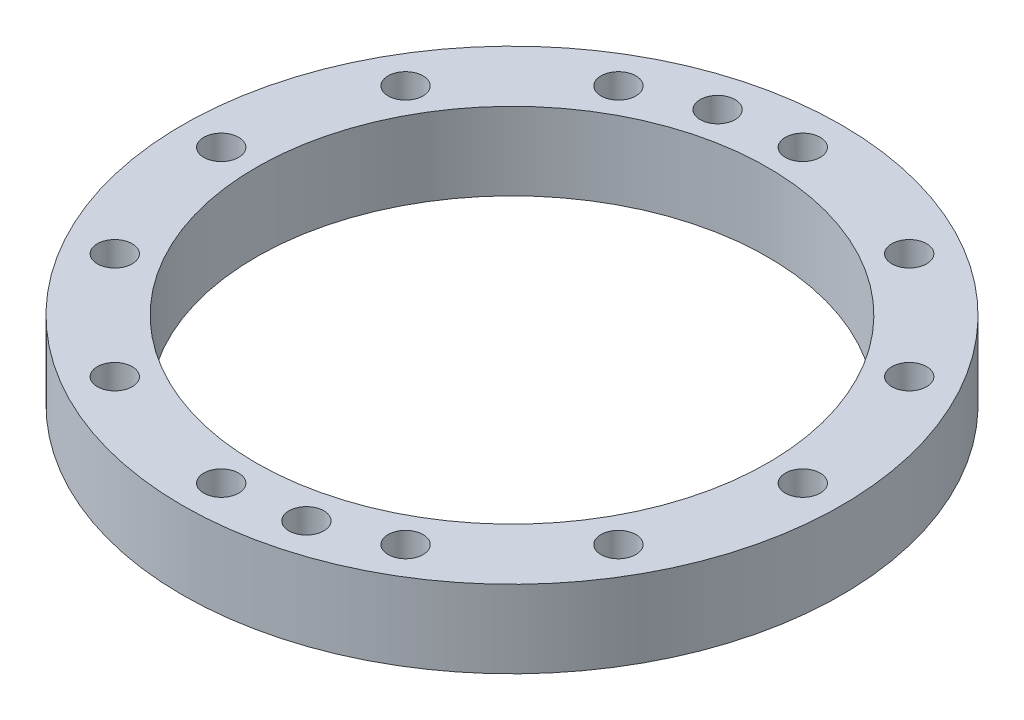
from build123d import *

# Parameters (mm, degrees)
SKETCH1_R           = 42.5
SKETCH1_R_2         = 33
BOSS_EXTRUDE1_DEPTH = 10
SKETCH2_R           = 2.25
CUT_EXTRUDE1_DEPTH  = 11
CIRPATTERN1_COUNT   = 12
SKETCH3_R           = 2.25
CUT_EXTRUDE2_DEPTH  = 11
CIRPATTERN2_COUNT   = 2


with BuildPart() as part:
    # Sketch1 → Boss-Extrude1 (new body)
    with BuildSketch(Plane(origin=(0, 0, 0), x_dir=(1, 0, 0), z_dir=(0, 1, 0))):
        Circle(SKETCH1_R)
        Circle(SKETCH1_R_2, mode=Mode.SUBTRACT)
    extrude(amount=BOSS_EXTRUDE1_DEPTH)

    # Sketch2 → Cut-Extrude1 (cut, through all)
    with BuildSketch(Plane(origin=(0, 10, 0), x_dir=(1, 0, 0), z_dir=(0, 1, 0))):
        with Locations((0, 37.5)):
            Circle(SKETCH2_R)
    cut_extrude1 = extrude(amount=-CUT_EXTRUDE1_DEPTH, mode=Mode.SUBTRACT)

    # CirPattern1: Cut-Extrude1 ×12 about axis
    cirpattern1_axis = Axis((0, 0, 0), (0, 1, 0))
    for i in range(1, CIRPATTERN1_COUNT):
        add(cut_extrude1.rotate(cirpattern1_axis, i * 360 / CIRPATTERN1_COUNT), mode=Mode.SUBTRACT)

    # Sketch3 → Cut-Extrude2 (cut, through all)
    with BuildSketch(Plane(origin=(0, 10, 0), x_dir=(1, 0, 0), z_dir=(0, 1, 0))):
        with Locations((-9.705714191, 36.222218486)):
            Circle(SKETCH3_R)
    cut_extrude2 = extrude(amount=-CUT_EXTRUDE2_DEPTH, mode=Mode.SUBTRACT)

    # CirPattern2: Cut-Extrude2 ×2 about axis
    cirpattern2_axis = Axis((0, 0, 0), (0, 1, 0))
    for i in range(1, CIRPATTERN2_COUNT):
        add(cut_extrude2.rotate(cirpattern2_axis, i * 360 / CIRPATTERN2_COUNT), mode=Mode.SUBTRACT)


solid = part.part
